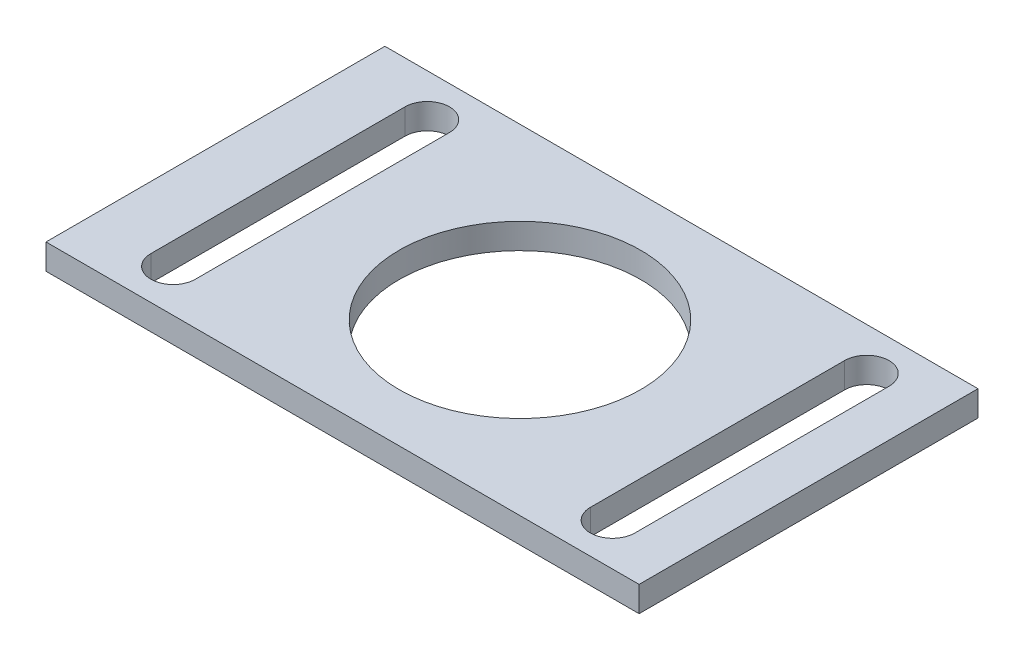
from build123d import *

# Parameters (mm, degrees)
SKETCH1_W           = 70
SKETCH1_H           = 40
BOSS_EXTRUDE1_DEPTH = 3
SKETCH2_R           = 14.255
CUT_EXTRUDE1_DEPTH  = 3


with BuildPart() as part:
    # Sketch1 → Boss-Extrude1 (new body)
    with BuildSketch(Plane(origin=(0, 0, 0), x_dir=(1, 0, 0), z_dir=(0, 1, 0))):
        with Locations((35, 20)):
            Rectangle(SKETCH1_W, SKETCH1_H)
    extrude(amount=BOSS_EXTRUDE1_DEPTH)

    # Sketch2 → Cut-Extrude1 (cut)
    with BuildSketch(Plane(origin=(0, 3, 0), x_dir=(1, 0, 0), z_dir=(0, 1, 0))):
        with Locations((35.9375, 20)):
            Circle(SKETCH2_R)
        with BuildLine():
            Line((12.625, 35), (12.625, 5))
            ThreePointArc((12.625, 5), (10, 2.375), (7.375, 5))
            Line((7.375, 5), (7.375, 35))
            ThreePointArc((7.375, 35), (10, 37.625), (12.625, 35))
        make_face()
        with BuildLine():
            Line((64.5, 35), (64.5, 5))
            ThreePointArc((64.5, 5), (61.875, 2.375), (59.25, 5))
            Line((59.25, 5), (59.25, 35))
            ThreePointArc((59.25, 35), (61.875, 37.625), (64.5, 35))
        make_face()
    extrude(amount=-CUT_EXTRUDE1_DEPTH, mode=Mode.SUBTRACT)


solid = part.part
